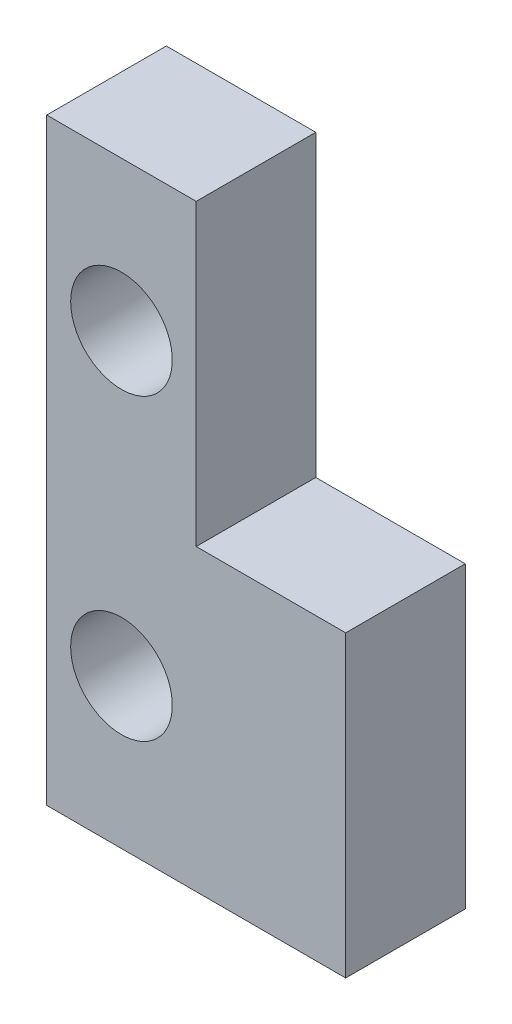
from build123d import *

# Parameters (mm, degrees)
ESQUISSE1_W             = 10
ESQUISSE1_H             = 20
BOSS_EXTRU_1_DEPTH      = 4
D_GAGEMENT_M33_D        = 3.4
ESQUISSE2_W             = 5
ESQUISSE2_H             = 10
ENL_V_MAT_EXTRU_2_DEPTH = 4


with BuildPart() as part:
    # Esquisse1 → Boss.-Extru.1 (new body)
    with BuildSketch(Plane.XY):
        Rectangle(ESQUISSE1_W, ESQUISSE1_H)
    extrude(amount=BOSS_EXTRU_1_DEPTH)

    # Dégagement M33 (through all)
    with Locations(Plane(origin=(0, 0, 0), x_dir=(-1, 0, 0), z_dir=(0, 0, -1))):
        with Locations((2.5, 5), (2.5, -5)):
            Hole(D_GAGEMENT_M33_D / 2)

    # Esquisse2 → Enlèv. mat.-Extru.2 (cut)
    with BuildSketch(Plane(origin=(0, 0, 0), x_dir=(-1, 0, 0), z_dir=(0, 0, -1))):
        with Locations((-2.5, 5)):
            Rectangle(ESQUISSE2_W, ESQUISSE2_H)
    extrude(amount=-ENL_V_MAT_EXTRU_2_DEPTH, mode=Mode.SUBTRACT)


solid = part.part
